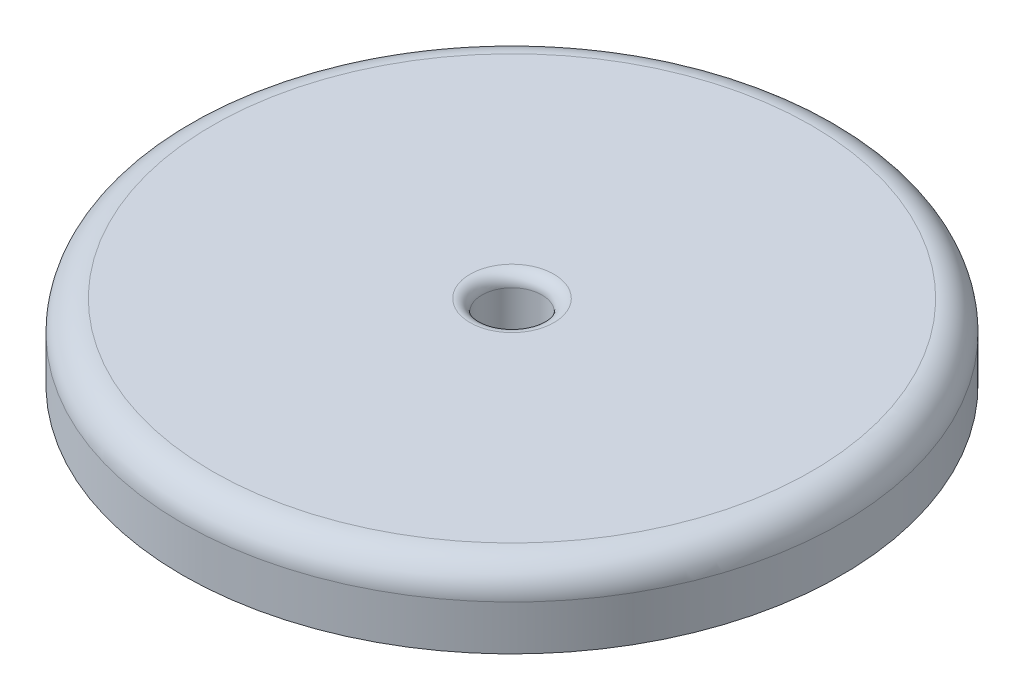
from build123d import *

# Parameters (mm, degrees)
SKETCH_1_R          = 11
EXTRUDE_1_DEPTH     = 2.5
SKETCH_2_R          = 1
CUT_EXTRUDE_1_DEPTH = 3.5
FILLET_1_R          = 0.4
FILLET_2_R          = 1
SKETCH_3_R          = 9.5
SKETCH_3_R_2        = 1
EXTRUDE_2_DEPTH     = 0.5
FILLET_3_R          = 0.2


with BuildPart() as part:
    # 草图1 → 凸台-拉伸1 (new body)
    with BuildSketch(Plane(origin=(0, 0, 0), x_dir=(1, 0, 0), z_dir=(0, 1, 0))):
        Circle(SKETCH_1_R)
    extrude(amount=EXTRUDE_1_DEPTH)

    # 草图2 → 切除-拉伸1 (cut, through all)
    with BuildSketch(Plane(origin=(0, 2.5, 0), x_dir=(1, 0, 0), z_dir=(0, 1, 0))):
        Circle(SKETCH_2_R)
    extrude(amount=-CUT_EXTRUDE_1_DEPTH, mode=Mode.SUBTRACT)

    # 圆角1
    fillet_1_edges = [part.edges().sort_by_distance(p)[0] for p in [
        (-1, 2.5, 0),
    ]]
    fillet(fillet_1_edges, radius=FILLET_1_R)

    # 圆角2
    fillet_2_edges = [part.edges().sort_by_distance(p)[0] for p in [
        (-11, 2.5, 0),
    ]]
    fillet(fillet_2_edges, radius=FILLET_2_R)

    # 草图3 → 凸台-拉伸2 (add)
    with BuildSketch(Plane.XZ):
        Circle(SKETCH_3_R)
        Circle(SKETCH_3_R_2, mode=Mode.SUBTRACT)
    extrude(amount=EXTRUDE_2_DEPTH)

    # 圆角3
    fillet_3_edges = [part.edges().sort_by_distance(p)[0] for p in [
        (-9.5, 0, 0),
        (-9.5, -0.5, 0),
    ]]
    fillet(fillet_3_edges, radius=FILLET_3_R)


solid = part.part
